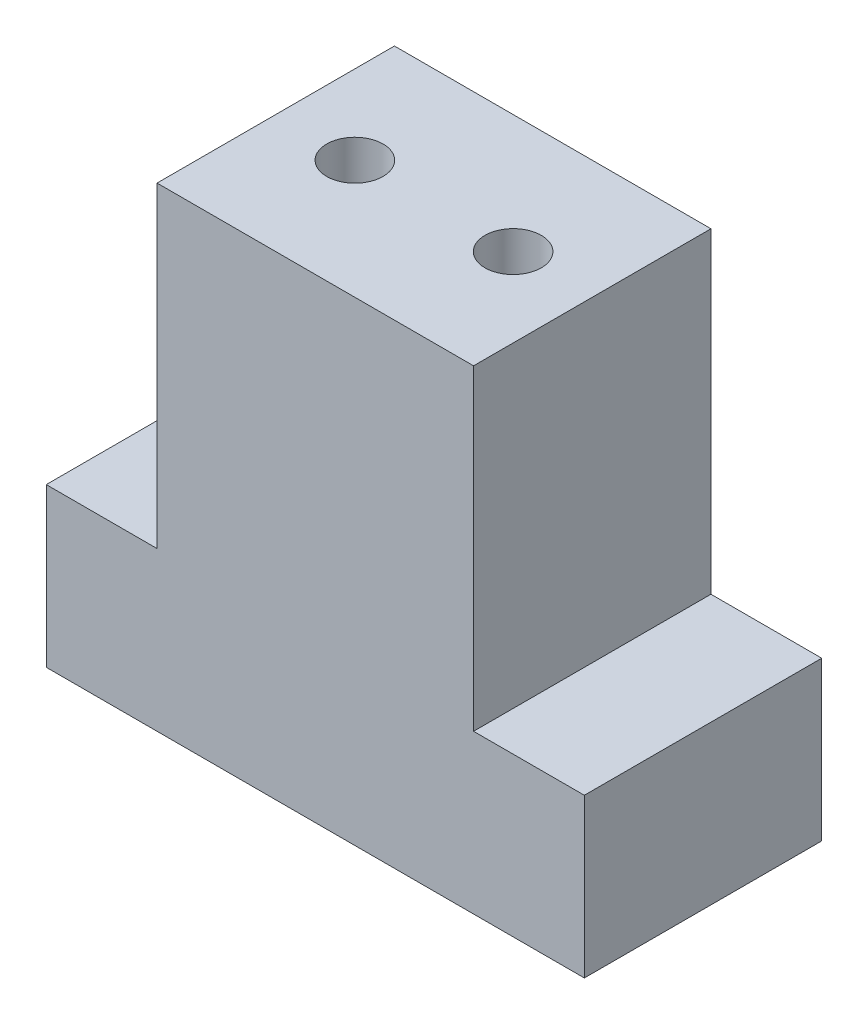
from build123d import *

# Parameters (mm, degrees)
SKETCH1_W           = 12.7
SKETCH1_H           = 9.525
BOSS_EXTRUDE1_DEPTH = 12.7
SKETCH2_R           = 1.1303
CUT_EXTRUDE1_DEPTH  = 6.35
SKETCH3_W           = 21.59
SKETCH3_H           = 9.525
BOSS_EXTRUDE2_DEPTH = 6.35
SKETCH4_R           = 1.1303
CUT_EXTRUDE2_DEPTH  = 6.35


with BuildPart() as part:
    # Sketch1 → Boss-Extrude1 (new body)
    with BuildSketch(Plane(origin=(0, 0, 0), x_dir=(1, 0, 0), z_dir=(0, 1, 0))):
        Rectangle(SKETCH1_W, SKETCH1_H)
    extrude(amount=BOSS_EXTRUDE1_DEPTH)

    # Sketch2 → Cut-Extrude1 (cut)
    with BuildSketch(Plane(origin=(0, 12.7, 0), x_dir=(1, 0, 0), z_dir=(0, 1, 0))):
        with Locations((-3.175, 0)):
            Circle(SKETCH2_R)
        with Locations((3.175, 0)):
            Circle(SKETCH2_R)
    extrude(amount=-CUT_EXTRUDE1_DEPTH, mode=Mode.SUBTRACT)

    # Sketch3 → Boss-Extrude2 (add)
    with BuildSketch(Plane.XZ):
        Rectangle(SKETCH3_W, SKETCH3_H)
    extrude(amount=BOSS_EXTRUDE2_DEPTH)

    # Sketch4 → Cut-Extrude2 (cut)
    with BuildSketch(Plane.XZ.offset(6.35)):
        with Locations((-4.7625, 0)):
            Circle(SKETCH4_R)
        with Locations((4.7625, 0)):
            Circle(SKETCH4_R)
    extrude(amount=-CUT_EXTRUDE2_DEPTH, mode=Mode.SUBTRACT)


solid = part.part
